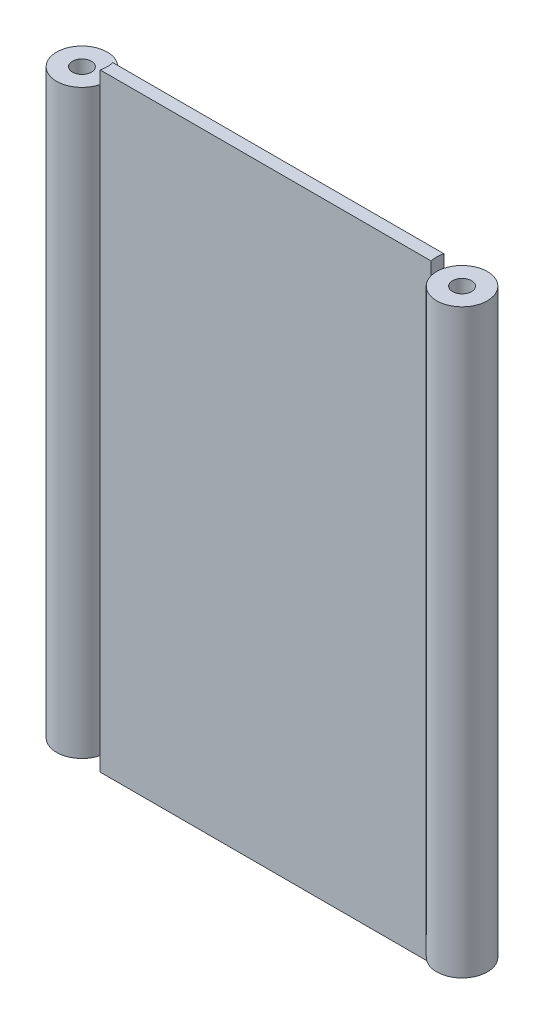
from build123d import *

# Parameters (mm, degrees)
SKETCH1_R           = 2.38125
BOSS_EXTRUDE1_DEPTH = 152.4
SKETCH2_R           = 6.35
CUT_EXTRUDE1_DEPTH  = 3.571875
SKETCH3_R           = 6.35
CUT_EXTRUDE3_DEPTH  = 3.175


with BuildPart() as part:
    # Sketch1 → Boss-Extrude1 (new body)
    with BuildSketch(Plane(origin=(0, 0, 0), x_dir=(1, 0, 0), z_dir=(0, 1, 0))):
        with BuildLine():
            Line((-41.476638938, 3.175), (0, 3.175))
            Line((0, 3.175), (0, 0))
            Line((0, 0), (-41.476638938, 0))
            ThreePointArc((-41.476638938, 0), (-53.975, 1.5875), (-41.476638938, 3.175))
        make_face()
        with Locations((-47.625, 1.5875)):
            Circle(SKETCH1_R, mode=Mode.SUBTRACT)
    boss_extrude1 = extrude(amount=BOSS_EXTRUDE1_DEPTH)

    # Sketch2 → Cut-Extrude1 (cut)
    with BuildSketch(Plane.XZ):
        with Locations((-47.625, -1.5875)):
            Circle(SKETCH2_R)
    cut_extrude1 = extrude(amount=-CUT_EXTRUDE1_DEPTH, mode=Mode.SUBTRACT)

    # Sketch3 → Cut-Extrude3 (cut)
    with BuildSketch(Plane(origin=(0, 152.4, 0), x_dir=(1, 0, 0), z_dir=(0, 1, 0))):
        with Locations((-47.625, 1.5875)):
            Circle(SKETCH3_R)
    cut_extrude3 = extrude(amount=-CUT_EXTRUDE3_DEPTH, mode=Mode.SUBTRACT)

    # Mirror2: Boss-Extrude1, Cut-Extrude1, Cut-Extrude3 across plane
    add(boss_extrude1.mirror(Plane(origin=(0, 152.4, -3.175), x_dir=(0, 0, 1), z_dir=(1, 0, 0))))
    add(cut_extrude1.mirror(Plane(origin=(0, 152.4, -3.175), x_dir=(0, 0, 1), z_dir=(1, 0, 0))), mode=Mode.SUBTRACT)
    add(cut_extrude3.mirror(Plane(origin=(0, 152.4, -3.175), x_dir=(0, 0, 1), z_dir=(1, 0, 0))), mode=Mode.SUBTRACT)


solid = part.part
